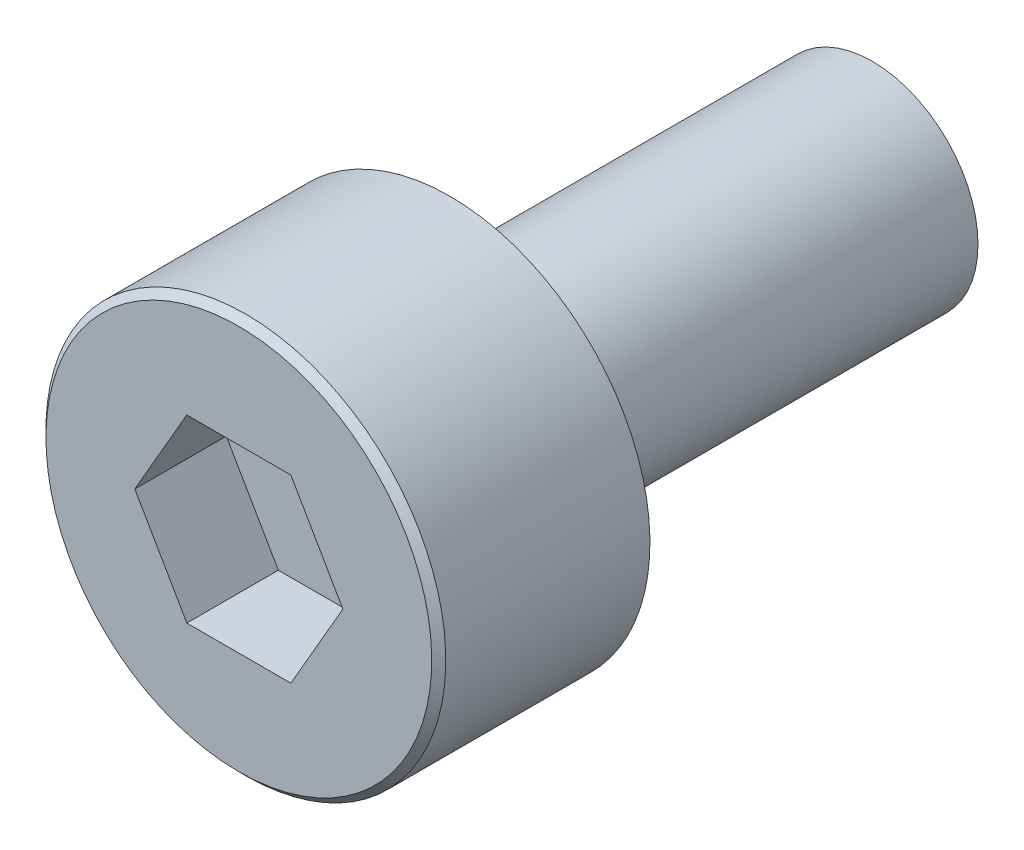
from build123d import *

# Parameters (mm, degrees)
CUT_EXTRUDE_1_DEPTH = 1.3
CHAMFER_628_SIZE    = 0.1


with BuildPart() as part:
    # 草图1 → 旋转1 (revolve)
    with BuildSketch(Plane(origin=(0, 0, 0), x_dir=(0, 0, -1), z_dir=(1, 0, 0))):
        Polygon((0, 0), (0, 2.84), (3, 2.84), (3, 1.5), (9, 1.5), (9, 0), align=None)
    revolve(axis=Axis((0, 0, -9), (0, 0, 1)))

    # 草图2 → 切除-拉伸1 (cut)
    with BuildSketch(Plane.XY):
        Polygon((0.739008345, 1.28), (-0.739008345, 1.28), (-1.478016689, 0), (-0.739008345, -1.28), (0.739008345, -1.28), (1.478016689, 0), align=None)
    extrude(amount=-CUT_EXTRUDE_1_DEPTH, mode=Mode.SUBTRACT)

    # Chamfer 628
    chamfer_628_edges = [part.edges().sort_by_distance(p)[0] for p in [
        (0, -2.84, 0),
    ]]
    chamfer(chamfer_628_edges, length=CHAMFER_628_SIZE)


solid = part.part
